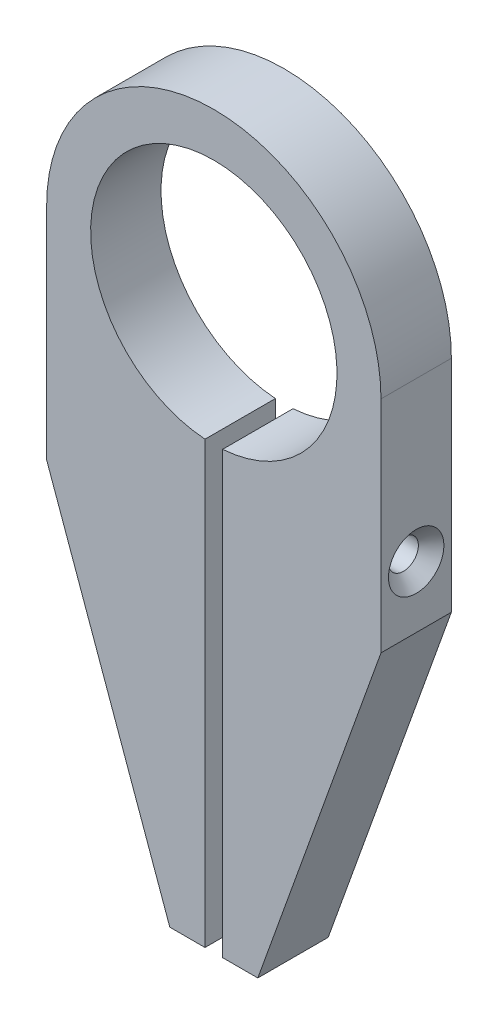
from build123d import *

# Parameters (mm, degrees)
EXTRUDE_1_DEPTH              = 8
HOLE_WIZARD_M3_1_D           = 3.4
HOLE_WIZARD_M3_1_DEPTH       = 18
HOLE_WIZARD_M3_1_CSINK_D     = 6.3
HOLE_WIZARD_M3_1_CSINK_ANGLE = 90
HOLE_WIZARD_M3_1_2_D         = 2.5
HOLE_WIZARD_M3_1_2_DEPTH     = 18


with BuildPart() as part:
    # 스케치1 → 보스-돌출1 (new body)
    with BuildSketch(Plane.XY):
        with BuildLine():
            Line((1, -13.964240044), (1, -64))
            Line((1, -64), (5, -64))
            Line((5, -64), (19, -25))
            Line((19, -25), (19, 0))
            ThreePointArc((19, 0), (0, 19), (-19, 0))
            Line((-19, 0), (-19, -25))
            Line((-19, -25), (-5, -64))
            Line((-5, -64), (-1, -64))
            Line((-1, -64), (-1, -13.964240044))
            ThreePointArc((-1, -13.964240044), (0, 14), (1, -13.964240044))
        make_face()
    extrude(amount=EXTRUDE_1_DEPTH)

    # Hole Wizard M3 _ _ _ _1
    with Locations(Plane(origin=(19, 0, 0), x_dir=(0, 0, -1), z_dir=(1, 0, 0))):
        with Locations((-4, -18)):
            CounterSinkHole(HOLE_WIZARD_M3_1_D / 2, HOLE_WIZARD_M3_1_CSINK_D / 2, depth=HOLE_WIZARD_M3_1_DEPTH, counter_sink_angle=HOLE_WIZARD_M3_1_CSINK_ANGLE)

    # Hole Wizard M3 _ _1 2
    with Locations(Plane.ZY.offset(19)):
        with Locations((4, -18)):
            Hole(HOLE_WIZARD_M3_1_2_D / 2, depth=HOLE_WIZARD_M3_1_2_DEPTH)


solid = part.part
